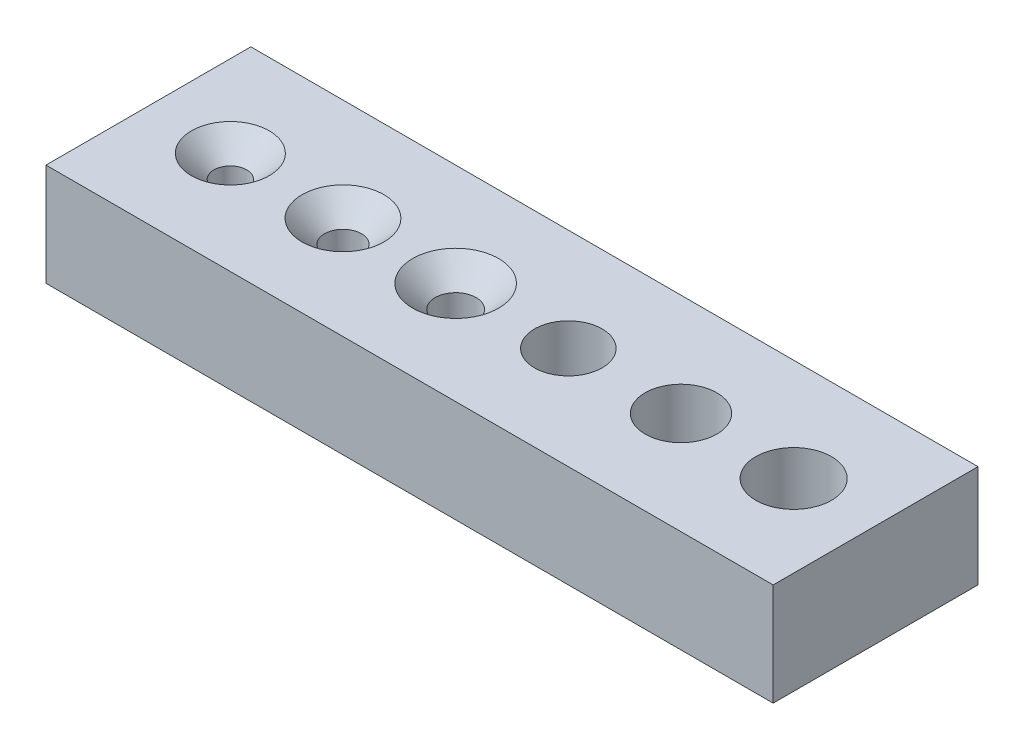
from build123d import *

# Parameters (mm, degrees)
SKETCH1_W                             = 35.5
SKETCH1_H                             = 10
BOSS_EXTRUDE1_DEPTH                   = 5
TAP_DRILL_FOR_M2X0_4_TAP1_D           = 1.8
TAP_DRILL_FOR_M2X0_4_TAP1_DEPTH       = 7
TAP_DRILL_FOR_M2X0_4_TAP1_CSINK_D     = 4
TAP_DRILL_FOR_M2X0_4_TAP1_CSINK_ANGLE = 90
TAP_DRILL_FOR_M2X0_4_TAP1_TIP         = 0.540774557
TAP_DRILL_FOR_M2X0_4_TAP2_D           = 2
TAP_DRILL_FOR_M2X0_4_TAP2_DEPTH       = 7
TAP_DRILL_FOR_M2X0_4_TAP2_CSINK_D     = 4.2
TAP_DRILL_FOR_M2X0_4_TAP2_CSINK_ANGLE = 90
TAP_DRILL_FOR_M2X0_4_TAP2_TIP         = 0.600860619
TAP_DRILL_FOR_M2X0_4_TAP3_D           = 1.6
TAP_DRILL_FOR_M2X0_4_TAP3_DEPTH       = 7
TAP_DRILL_FOR_M2X0_4_TAP3_CSINK_D     = 3.8
TAP_DRILL_FOR_M2X0_4_TAP3_CSINK_ANGLE = 90
TAP_DRILL_FOR_M2X0_4_TAP3_TIP         = 0.480688495
TAP_DRILL_FOR_M4X0_7_TAP1_D           = 3.3
TAP_DRILL_FOR_M4X0_7_TAP1_DEPTH       = 5
TAP_DRILL_FOR_M4X0_7_TAP1_TIP         = 0.991420021
TAP_DRILL_FOR_M4X0_7_TAP2_D           = 3.5
TAP_DRILL_FOR_M4X0_7_TAP2_DEPTH       = 5
TAP_DRILL_FOR_M4X0_7_TAP2_TIP         = 1.051506083
TAP_DRILL_FOR_M4X0_7_TAP3_D           = 3.7
TAP_DRILL_FOR_M4X0_7_TAP3_DEPTH       = 5
TAP_DRILL_FOR_M4X0_7_TAP3_TIP         = 1.111592145


with BuildPart() as part:
    # Sketch1 → Boss-Extrude1 (new body)
    with BuildSketch(Plane(origin=(0, 0, 0), x_dir=(1, 0, 0), z_dir=(0, 1, 0))):
        with Locations((17.75, 5)):
            Rectangle(SKETCH1_W, SKETCH1_H)
    extrude(amount=BOSS_EXTRUDE1_DEPTH)

    # Tap Drill for M2x0.4 Tap1
    with Locations(Plane(origin=(9.5, 5, -5), x_dir=(0, 0, 1), z_dir=(0, 1, 0))):
        with Locations((0, 0)):
            CounterSinkHole(TAP_DRILL_FOR_M2X0_4_TAP1_D / 2, TAP_DRILL_FOR_M2X0_4_TAP1_CSINK_D / 2, depth=TAP_DRILL_FOR_M2X0_4_TAP1_DEPTH, counter_sink_angle=TAP_DRILL_FOR_M2X0_4_TAP1_CSINK_ANGLE)
            with Locations((0, 0, -(TAP_DRILL_FOR_M2X0_4_TAP1_DEPTH + TAP_DRILL_FOR_M2X0_4_TAP1_TIP / 2))):  # 118° drill point
                Cone(0, TAP_DRILL_FOR_M2X0_4_TAP1_D / 2, TAP_DRILL_FOR_M2X0_4_TAP1_TIP, mode=Mode.SUBTRACT)

    # Tap Drill for M2x0.4 Tap2
    with Locations(Plane(origin=(15, 5, -5), x_dir=(0, 0, 1), z_dir=(0, 1, 0))):
        with Locations((0, 0)):
            CounterSinkHole(TAP_DRILL_FOR_M2X0_4_TAP2_D / 2, TAP_DRILL_FOR_M2X0_4_TAP2_CSINK_D / 2, depth=TAP_DRILL_FOR_M2X0_4_TAP2_DEPTH, counter_sink_angle=TAP_DRILL_FOR_M2X0_4_TAP2_CSINK_ANGLE)
            with Locations((0, 0, -(TAP_DRILL_FOR_M2X0_4_TAP2_DEPTH + TAP_DRILL_FOR_M2X0_4_TAP2_TIP / 2))):  # 118° drill point
                Cone(0, TAP_DRILL_FOR_M2X0_4_TAP2_D / 2, TAP_DRILL_FOR_M2X0_4_TAP2_TIP, mode=Mode.SUBTRACT)

    # Tap Drill for M2x0.4 Tap3
    with Locations(Plane(origin=(4, 5, -5), x_dir=(0, 0, 1), z_dir=(0, 1, 0))):
        with Locations((0, 0)):
            CounterSinkHole(TAP_DRILL_FOR_M2X0_4_TAP3_D / 2, TAP_DRILL_FOR_M2X0_4_TAP3_CSINK_D / 2, depth=TAP_DRILL_FOR_M2X0_4_TAP3_DEPTH, counter_sink_angle=TAP_DRILL_FOR_M2X0_4_TAP3_CSINK_ANGLE)
            with Locations((0, 0, -(TAP_DRILL_FOR_M2X0_4_TAP3_DEPTH + TAP_DRILL_FOR_M2X0_4_TAP3_TIP / 2))):  # 118° drill point
                Cone(0, TAP_DRILL_FOR_M2X0_4_TAP3_D / 2, TAP_DRILL_FOR_M2X0_4_TAP3_TIP, mode=Mode.SUBTRACT)

    # Tap Drill for M4x0.7 Tap1
    with Locations(Plane(origin=(20.5, 5, -5), x_dir=(0, 0, 1), z_dir=(0, 1, 0))):
        with Locations((0, 0)):
            Hole(TAP_DRILL_FOR_M4X0_7_TAP1_D / 2, depth=TAP_DRILL_FOR_M4X0_7_TAP1_DEPTH)
            with Locations((0, 0, -(TAP_DRILL_FOR_M4X0_7_TAP1_DEPTH + TAP_DRILL_FOR_M4X0_7_TAP1_TIP / 2))):  # 118° drill point
                Cone(0, TAP_DRILL_FOR_M4X0_7_TAP1_D / 2, TAP_DRILL_FOR_M4X0_7_TAP1_TIP, mode=Mode.SUBTRACT)

    # Tap Drill for M4x0.7 Tap2
    with Locations(Plane(origin=(26, 5, -5), x_dir=(0, 0, 1), z_dir=(0, 1, 0))):
        with Locations((0, 0)):
            Hole(TAP_DRILL_FOR_M4X0_7_TAP2_D / 2, depth=TAP_DRILL_FOR_M4X0_7_TAP2_DEPTH)
            with Locations((0, 0, -(TAP_DRILL_FOR_M4X0_7_TAP2_DEPTH + TAP_DRILL_FOR_M4X0_7_TAP2_TIP / 2))):  # 118° drill point
                Cone(0, TAP_DRILL_FOR_M4X0_7_TAP2_D / 2, TAP_DRILL_FOR_M4X0_7_TAP2_TIP, mode=Mode.SUBTRACT)

    # Tap Drill for M4x0.7 Tap3
    with Locations(Plane(origin=(31.5, 5, -5), x_dir=(0, 0, 1), z_dir=(0, 1, 0))):
        with Locations((0, 0)):
            Hole(TAP_DRILL_FOR_M4X0_7_TAP3_D / 2, depth=TAP_DRILL_FOR_M4X0_7_TAP3_DEPTH)
            with Locations((0, 0, -(TAP_DRILL_FOR_M4X0_7_TAP3_DEPTH + TAP_DRILL_FOR_M4X0_7_TAP3_TIP / 2))):  # 118° drill point
                Cone(0, TAP_DRILL_FOR_M4X0_7_TAP3_D / 2, TAP_DRILL_FOR_M4X0_7_TAP3_TIP, mode=Mode.SUBTRACT)


solid = part.part
